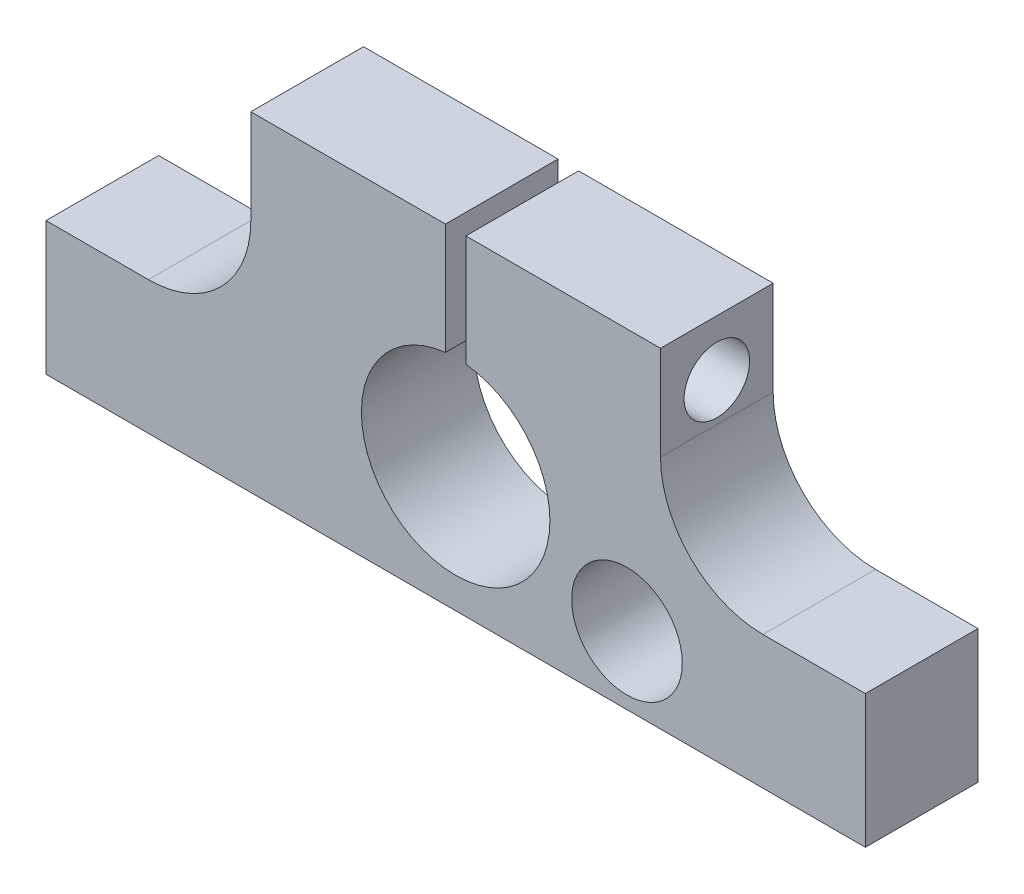
from build123d import *

# Parameters (mm, degrees)
SZKIC1_W                        = 10
SZKIC1_H                        = 6.5
DODANIE_WYCI_GNI_CIE1_DEPTH     = 5.5
WYTNIJ_WYCI_GNI_CIE1_REACH      = 28.258
WYTNIJ_WYCI_GNI_CIE1_END_RADIUS = 4.600818815
SZKIC2_W                        = 1
SZKIC2_H                        = 5.5
OTW_R_GWINTOWANY_M3X0_51_D      = 2.5
OTW_R_POD_RUB_M31_REACH         = 34.098
OTW_R_POD_RUB_M31_BORE_R        = 1.6
SZKIC10_R                       = 2.7
WYTNIJ_WYCI_GNI_CIE2_DEPTH      = 24.027157879
ZAOKR_GLENIE1_R                 = 5


with BuildPart() as part:
    # Szkic1 → Dodanie-wyciągnięcie1 (new body)
    with BuildSketch(Plane.XY):
        with BuildLine():
            Line((10, 6.1), (-10, 6.1))
            Line((-10, 6.1), (-10, -3.5))
            Line((-10, -3.5), (-4.583397623, -3.5))
            ThreePointArc((-4.583397623, -3.5), (0, 0.700818815), (4.583397623, -3.5))
            Line((4.583397623, -3.5), (10, -3.5))
            Line((10, -3.5), (10, 6.1))
        make_face()
        with Locations((-15, -6.75)):
            Rectangle(SZKIC1_W, SZKIC1_H)
        with BuildLine():
            Line((-4.583397623, -3.5), (-10, -3.5))
            Line((-10, -3.5), (-10, -10))
            Line((-10, -10), (10, -10))
            Line((10, -10), (10, -3.5))
            Line((10, -3.5), (4.583397623, -3.5))
            ThreePointArc((4.583397623, -3.5), (4.596461454, -3.699810404), (4.600818815, -3.9))
            ThreePointArc((4.600818815, -3.9), (-0.200189596, -8.496461454), (-4.583397623, -3.5))
        make_face()
        with Locations((15, -6.75)):
            Rectangle(SZKIC1_W, SZKIC1_H)
    extrude(amount=DODANIE_WYCI_GNI_CIE1_DEPTH)

    # Wytnij-wyciągnięcie1: up to this cylinder (the profile starts outside it)
    wytnij_wyci_gni_cie1_end = Plane(origin=(0, -3.9, 2.75), z_dir=(0, 0, -1)) * Cylinder(WYTNIJ_WYCI_GNI_CIE1_END_RADIUS, 66.717637631, mode=Mode.PRIVATE)
    # Szkic2 → Wytnij-wyciągnięcie1 (cut, up to the surface)
    with BuildSketch(Plane(origin=(0, 6.1, 0), x_dir=(1, 0, 0), z_dir=(0, 1, 0)), mode=Mode.PRIVATE) as wytnij_wyci_gni_cie1_sk1:
        with Locations((0, -2.75)):
            Rectangle(SZKIC2_W, SZKIC2_H)
    wytnij_wyci_gni_cie1_tool1 = extrude(wytnij_wyci_gni_cie1_sk1.sketch, amount=-WYTNIJ_WYCI_GNI_CIE1_REACH, mode=Mode.PRIVATE) - wytnij_wyci_gni_cie1_end
    add(wytnij_wyci_gni_cie1_tool1.solids().sort_by_distance((0, 6.1, 2.75))[0], mode=Mode.SUBTRACT)

    # Otwór gwintowany M3x0.51 (through all)
    with Locations(Plane(origin=(10, 0, 0), x_dir=(0, 0, -1), z_dir=(1, 0, 0))):
        with Locations((-2.75, 3.38678452)):
            Hole(OTW_R_GWINTOWANY_M3X0_51_D / 2)

    # Otwór pod śrubę M31 bore → Otwór pod śrubę M31 (cut, up to next)
    with BuildSketch(Plane(origin=(10, 0, 0), x_dir=(0, 0, -1), z_dir=(1, 0, 0)), mode=Mode.PRIVATE) as otw_r_pod_rub_m31_sk1:
        with Locations((-2.75, 3.38678452)):
            Circle(OTW_R_POD_RUB_M31_BORE_R)
    otw_r_pod_rub_m31_tool1 = extrude(otw_r_pod_rub_m31_sk1.sketch, amount=-OTW_R_POD_RUB_M31_REACH, mode=Mode.PRIVATE) & part.part
    add(otw_r_pod_rub_m31_tool1.solids().sort_by_distance((10, 3.386785, 2.75))[0], mode=Mode.SUBTRACT)

    # Szkic10 → Wytnij-wyciągnięcie2 (cut, through all)
    with BuildSketch(Plane.XY.offset(5.5)):
        with Locations((8.363131331, -6.679576829)):
            Circle(SZKIC10_R)
    extrude(amount=-WYTNIJ_WYCI_GNI_CIE2_DEPTH, mode=Mode.SUBTRACT)

    # Zaokrąglenie1
    zaokr_glenie1_edges = [part.edges().sort_by_distance(p)[0] for p in [
        (-10, -3.5, 2.75),
        (10, -3.5, 2.75),
    ]]
    fillet(zaokr_glenie1_edges, radius=ZAOKR_GLENIE1_R)


solid = part.part
